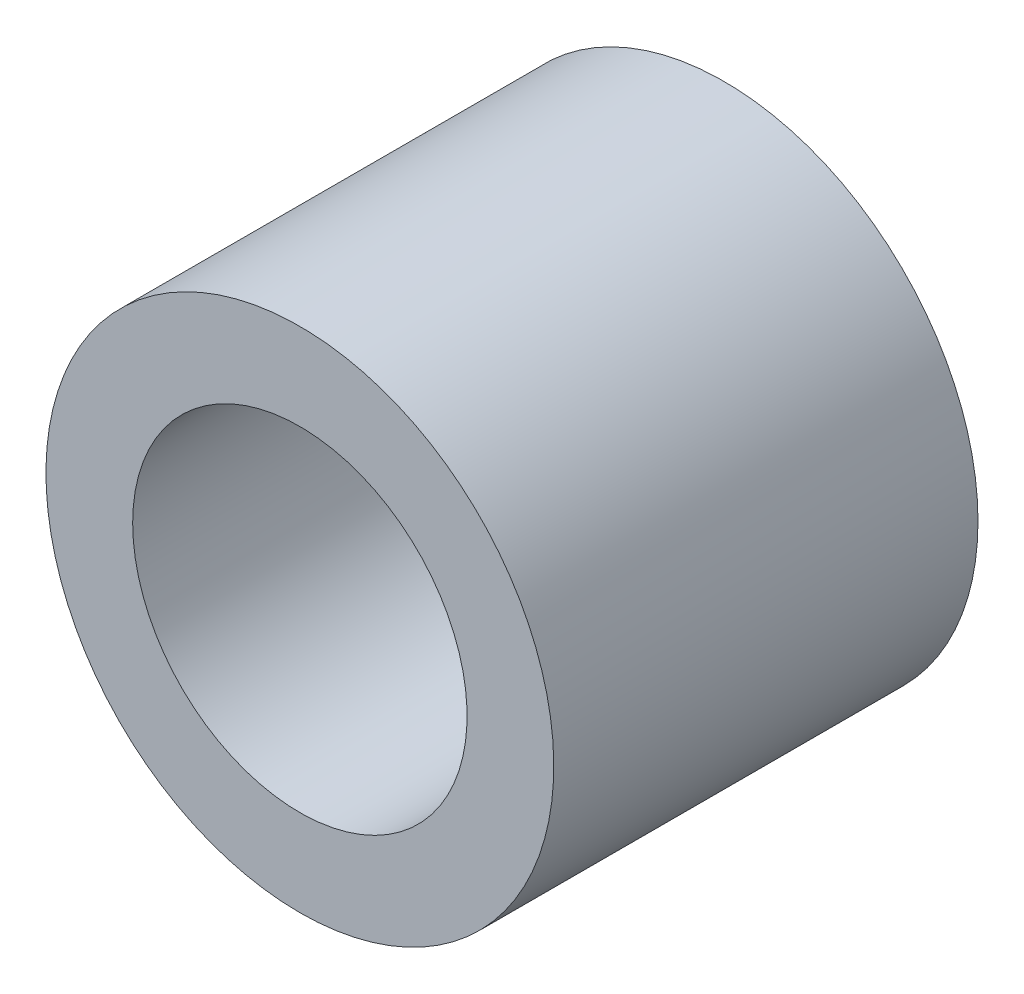
from build123d import *

# Parameters (mm, degrees)
SKETCH1_R            = 4.1
BOSS_EXTRUDE2_DEPTH  = 6.85
M5_CLEARANCE_HOLE1_D = 5.4


with BuildPart() as part:
    # Sketch1 → Boss-Extrude2 (new body)
    with BuildSketch(Plane.XY):
        with Locations((59.475545776, 35.570000001)):
            Circle(SKETCH1_R)
    extrude(amount=BOSS_EXTRUDE2_DEPTH)

    # M5 Clearance Hole1 (through all)
    with Locations(Plane(origin=(0, 0, 0), x_dir=(-1, 0, 0), z_dir=(0, 0, -1))):
        with Locations((-59.475545776, 35.570000001)):
            Hole(M5_CLEARANCE_HOLE1_D / 2)


solid = part.part
